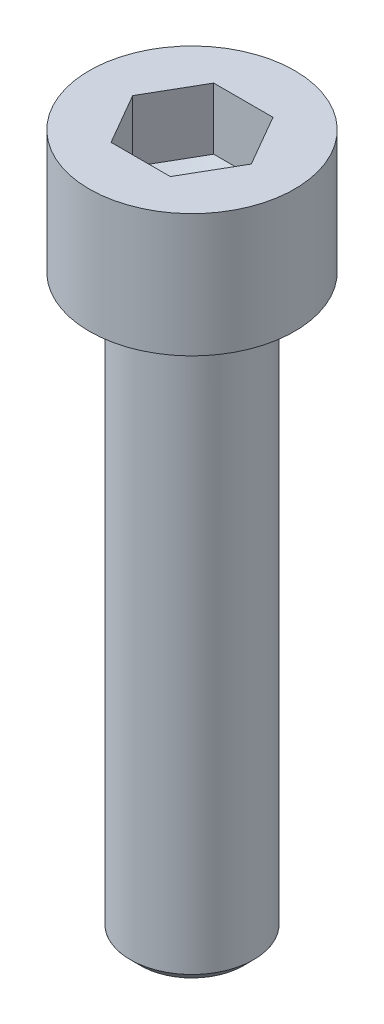
from build123d import *

# Parameters (mm, degrees)
SKETCH1_R           = 5
BOSS_EXTRUDE1_DEPTH = 6
CUT_EXTRUDE1_DEPTH  = 3
SKETCH4_R           = 3
BOSS_EXTRUDE2_DEPTH = 27.5
SKETCH5_R           = 3
BOSS_EXTRUDE3_DEPTH = 0.5
BOSS_EXTRUDE3_TAPER = 45


with BuildPart() as part:
    # Sketch1 → Boss-Extrude1 (new body)
    with BuildSketch(Plane(origin=(0, 0, 0), x_dir=(1, 0, 0), z_dir=(0, 1, 0))):
        with Locations(Location((0, 0, 0), (0, 0, 270))):
            Circle(SKETCH1_R)
    extrude(amount=BOSS_EXTRUDE1_DEPTH)

    # Sketch2 → Cut-Extrude1 (cut)
    with BuildSketch(Plane(origin=(0, 6, 0), x_dir=(1, 0, 0), z_dir=(0, 1, 0))):
        Polygon((2.886751346, 0), (1.443375673, 2.5), (-1.443375673, 2.5), (-2.886751346, 0), (-1.443375673, -2.5), (1.443375673, -2.5), align=None)
    extrude(amount=-CUT_EXTRUDE1_DEPTH, mode=Mode.SUBTRACT)

    # Cut-Extrude5 cone 1 section (through the dimple's axis) → Cut-Extrude5 (revolve, cut)
    with BuildSketch(Plane(origin=(0, 3, 0), x_dir=(0, 0, 1), z_dir=(1, 0, 0))):
        Polygon((0, 0), (2.886751346, 0), (0, 0.773502692), align=None)
    revolve(axis=Axis((0, 3, 0), (0, -1, 0)), mode=Mode.SUBTRACT)

    # Sketch4 → Boss-Extrude2 (add)
    with BuildSketch(Plane.XZ):
        with Locations(Location((0, 0, 0), (0, 0, 90))):
            Circle(SKETCH4_R)
    extrude(amount=BOSS_EXTRUDE2_DEPTH)


with BuildPart() as body_2:
    # Sketch5 → Boss-Extrude3 (new body)
    with BuildSketch(Plane.XZ.offset(27.5)):
        with Locations(Location((0, 0, 0), (0, 0, 90))):
            Circle(SKETCH5_R)
    extrude(amount=BOSS_EXTRUDE3_DEPTH, taper=BOSS_EXTRUDE3_TAPER)


solid = Compound([part.part, body_2.part])
